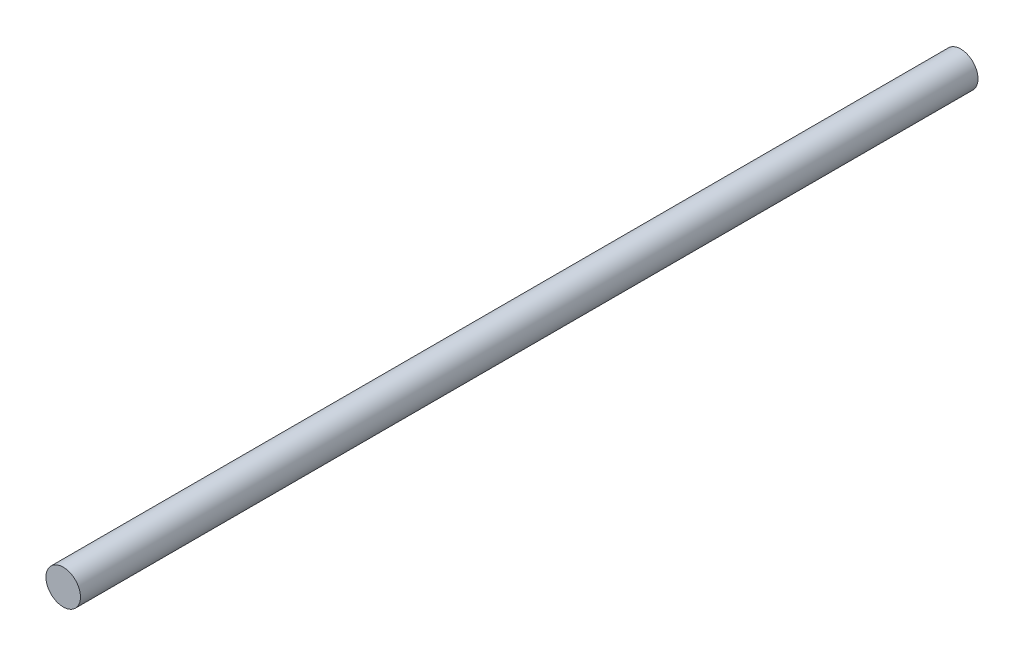
from build123d import *

# Parameters (mm, degrees)
ESQUISSE1_R        = 5
BOSS_EXTRU_2_DEPTH = 260


with BuildPart() as part:
    # Esquisse1 → Boss.-Extru.2 (new body)
    with BuildSketch(Plane.XY):
        with Locations((-19.014803002, 7.497720806)):
            Circle(ESQUISSE1_R)
    extrude(amount=BOSS_EXTRU_2_DEPTH)


solid = part.part
